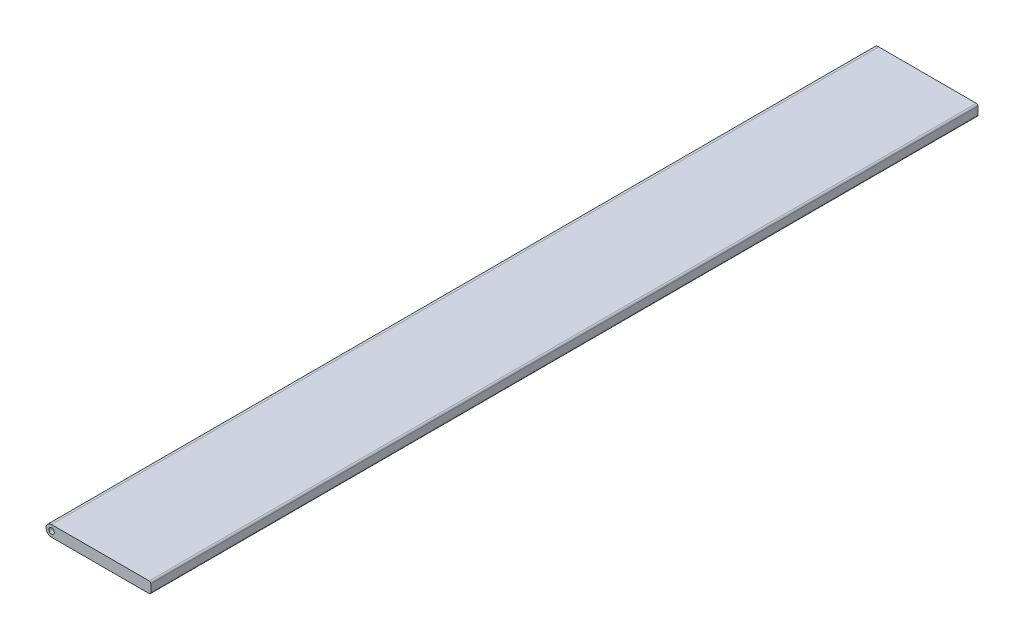
from build123d import *

# Parameters (mm, degrees)
SKETCH_1_R      = 0.5
EXTRUDE_1_DEPTH = 150
FILLET_1_R      = 0.3


with BuildPart() as part:
    # 草图1 → 凸台-拉伸1 (new body)
    with BuildSketch(Plane.XY):
        with BuildLine():
            Line((18, 1), (0, 1))
            ThreePointArc((0, 1), (-1, 0), (0, -1))
            Line((0, -1), (18, -1))
            Line((18, -1), (18, 1))
        make_face()
        Circle(SKETCH_1_R, mode=Mode.SUBTRACT)
    extrude(amount=EXTRUDE_1_DEPTH)

    # 圆角1
    fillet_1_edges = [part.edges().sort_by_distance(p)[0] for p in [
        (18, 1, 75),
        (18, -1, 75),
    ]]
    fillet(fillet_1_edges, radius=FILLET_1_R)


solid = part.part
